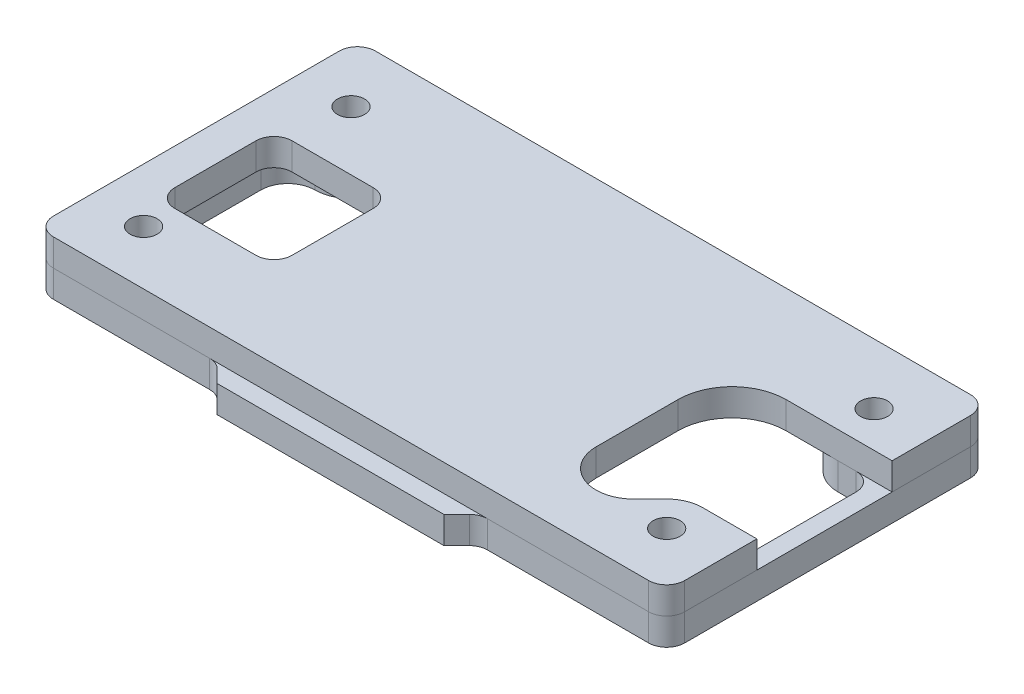
from build123d import *

# Parameters (mm, degrees)
SKETCH1_W           = 70
SKETCH1_H           = 35.7
SKETCH1_R           = 1.5
BOSS_EXTRUDE1_DEPTH = 3
SKETCH2_W           = 13
SKETCH2_H           = 13
CUT_EXTRUDE1_DEPTH  = 4
FILLET1_R           = 2
FILLET2_R           = 2
SKETCH3_R           = 1.5
BOSS_EXTRUDE2_DEPTH = 3
BOSS_EXTRUDE3_DEPTH = 3
FILLET3_R           = 2
FILLET4_R           = 2


with BuildPart() as part:
    # Sketch1 → Boss-Extrude1 (new body)
    with BuildSketch(Plane(origin=(0, 0, 0), x_dir=(1, 0, 0), z_dir=(0, 1, 0))):
        Rectangle(SKETCH1_W, SKETCH1_H)
        with Locations((-29, -11.85)):
            Circle(SKETCH1_R, mode=Mode.SUBTRACT)
        with Locations((29, -11.85)):
            Circle(SKETCH1_R, mode=Mode.SUBTRACT)
        with Locations((29, 11.15)):
            Circle(SKETCH1_R, mode=Mode.SUBTRACT)
        with Locations((-29, 11.15)):
            Circle(SKETCH1_R, mode=Mode.SUBTRACT)
    extrude(amount=BOSS_EXTRUDE1_DEPTH)

    # Sketch2 → Cut-Extrude1 (cut, through all)
    with BuildSketch(Plane(origin=(0, 3, 0), x_dir=(1, 0, 0), z_dir=(0, 1, 0))):
        with Locations((-24.5, -1.89)):
            Rectangle(SKETCH2_W, SKETCH2_H)
        with BuildLine():
            Line((17.25, 1.15), (17.25, -7.934129881))
            ThreePointArc((17.25, -7.934129881), (19.809314312, -11.764414428), (24.327442995, -10.865702756))
            Line((24.327442995, -10.865702756), (26.171572875, -9.021572875))
            ThreePointArc((26.171572875, -9.021572875), (27.469266271, -8.15448187), (29, -7.85))
            Line((29, -7.85), (35, -7.85))
            Line((35, -7.85), (35, 7.15))
            Line((35, 7.15), (23.25, 7.15))
            ThreePointArc((23.25, 7.15), (19.007359313, 5.392640687), (17.25, 1.15))
        make_face()
    extrude(amount=-CUT_EXTRUDE1_DEPTH, mode=Mode.SUBTRACT)

    # Fillet1
    fillet1_edges = [part.edges().sort_by_distance(p)[0] for p in [
        (-18, 1.5, -4.61),
        (-18, 1.5, 8.39),
        (-31, 1.5, 8.39),
        (-31, 1.5, -4.61),
    ]]
    fillet(fillet1_edges, radius=FILLET1_R)

    # Fillet2
    fillet2_edges = [part.edges().sort_by_distance(p)[0] for p in [
        (-35, 1.5, -17.85),
        (35, 1.5, -17.85),
        (35, 1.5, 17.85),
        (-35, 1.5, 17.85),
    ]]
    fillet(fillet2_edges, radius=FILLET2_R)


with BuildPart() as body_2:
    # Sketch3 → Boss-Extrude2 (new body)
    with BuildSketch(Plane.XZ):
        with BuildLine():
            Line((35, 15.85), (35, 7.85))
            Line((35, 7.85), (35, -7.15))
            Line((35, -7.15), (35, -15.85))
            ThreePointArc((35, -15.85), (34.414213562, -17.264213562), (33, -17.85))
            Line((33, -17.85), (-33, -17.85))
            ThreePointArc((-33, -17.85), (-34.414213562, -17.264213562), (-35, -15.85))
            Line((-35, -15.85), (-35, 15.85))
            ThreePointArc((-35, 15.85), (-34.414213562, 17.264213562), (-33, 17.85))
            Line((-33, 17.85), (-25.54, 17.85))
            Line((-25.54, 17.85), (-25.54, 11.85))
            ThreePointArc((-25.54, 11.85), (-26.553410537, 9.403410537), (-29, 8.39))
            Line((-29, 8.39), (-30, 8.39))
            ThreePointArc((-30, 8.39), (-31.414213562, 7.804213562), (-32, 6.39))
            Line((-32, 6.39), (-32, -4.15))
            ThreePointArc((-32, -4.15), (-31.121320344, -6.271320344), (-29, -7.15))
            ThreePointArc((-29, -7.15), (-26.171572875, -8.321572875), (-25, -11.15))
            Line((-25, -11.15), (-25, -12.85))
            ThreePointArc((-25, -12.85), (-24.414213562, -14.264213562), (-23, -14.85))
            Line((-23, -14.85), (23, -14.85))
            ThreePointArc((23, -14.85), (24.414213562, -14.264213562), (25, -12.85))
            Line((25, -12.85), (25, -11.15))
            ThreePointArc((25, -11.15), (26.171572875, -8.321572875), (29, -7.15))
            Line((29, -7.15), (31, -7.15))
            ThreePointArc((31, -7.15), (32.414213562, -6.564213562), (33, -5.15))
            Line((33, -5.15), (33, 5.85))
            ThreePointArc((33, 5.85), (32.414213562, 7.264213562), (31, 7.85))
            Line((31, 7.85), (29, 7.85))
            ThreePointArc((29, 7.85), (27.469266271, 8.15448187), (26.171572875, 9.021572875))
            ThreePointArc((26.171572875, 9.021572875), (25.30448187, 10.319266271), (25, 11.85))
            Line((25, 11.85), (25, 17.85))
            Line((25, 17.85), (33, 17.85))
            ThreePointArc((33, 17.85), (34.414213562, 17.264213562), (35, 15.85))
        make_face()
        with Locations((-29, 11.85)):
            Circle(SKETCH3_R, mode=Mode.SUBTRACT)
        with Locations((-29, -11.15)):
            Circle(SKETCH3_R, mode=Mode.SUBTRACT)
        with Locations((29, -11.15)):
            Circle(SKETCH3_R, mode=Mode.SUBTRACT)
        with Locations((29, 11.85)):
            Circle(SKETCH3_R, mode=Mode.SUBTRACT)
    extrude(amount=BOSS_EXTRUDE2_DEPTH)

    # Sketch4 → Boss-Extrude3 (add)
    with BuildSketch(Plane(origin=(0, 0, 0), x_dir=(1, 0, 0), z_dir=(0, 1, 0))):
        Polygon((-25.54, -15.85), (-9.77, -15.85), (-7.77, -17.85), (7.23, -17.85), (9.23, -15.85), (25, -15.85), (25, -17.85), (14.301067812, -17.85), (12.301067812, -19.85), (-12.841067812, -19.85), (-14.841067812, -17.85), (-25.54, -17.85), align=None)
    extrude(amount=-BOSS_EXTRUDE3_DEPTH)

    # Fillet3
    fillet3_edges = [body_2.edges().sort_by_distance(p)[0] for p in [
        (-25.54, -1.5, 15.85),
        (25, -1.5, 15.85),
    ]]
    fillet(fillet3_edges, radius=FILLET3_R)

    # Fillet4
    fillet4_edges = [body_2.edges().sort_by_distance(p)[0] for p in [
        (-7.77, -1.5, 17.85),
        (7.23, -1.5, 17.85),
        (14.301067812, -1.5, 17.85),
        (-14.841067812, -1.5, 17.85),
    ]]
    fillet(fillet4_edges, radius=FILLET4_R)


solid = Compound([part.part, body_2.part])
